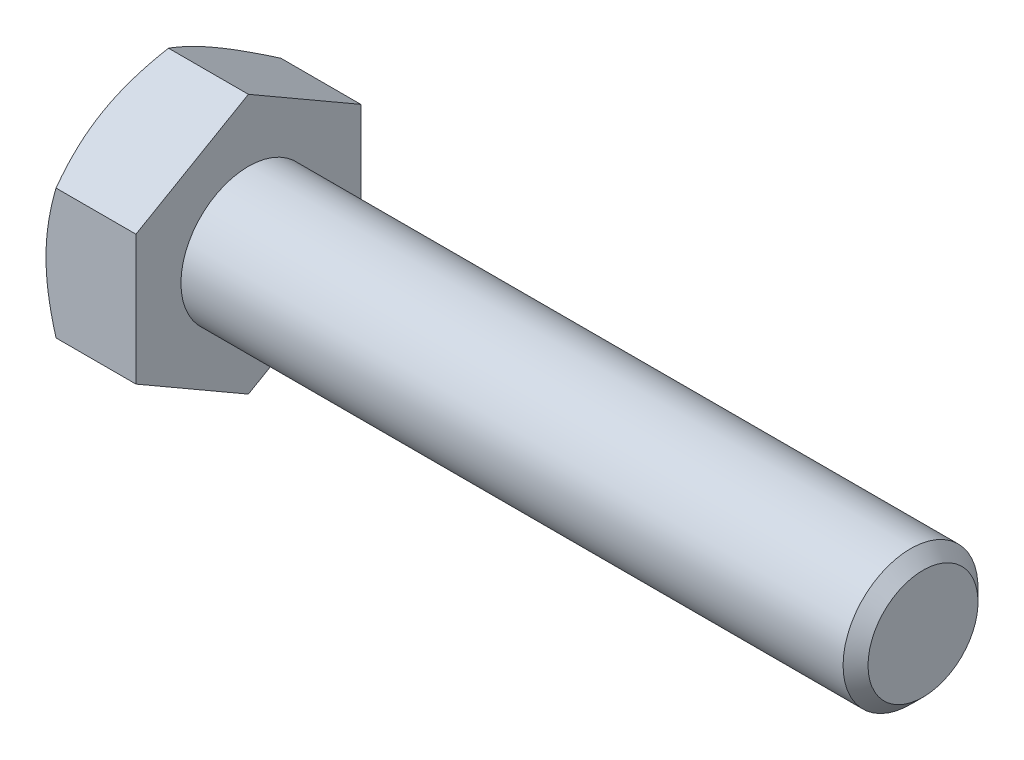
from build123d import *

# Parameters (mm, degrees)
BASEHEAD_DEPTH = 4


with BuildPart() as part:
    # Sketch1 → BaseHead (new body)
    with BuildSketch(Plane(origin=(0, 0, 0), x_dir=(0, 0, -1), z_dir=(1, 0, 0))):
        Polygon((5, 2.886751346), (5, -2.886751346), (0, -5.773502692), (-5, -2.886751346), (-5, 2.886751346), (0, 5.773502692), align=None)
    extrude(amount=BASEHEAD_DEPTH)

    # BodySke → BaseBody (revolve)
    with BuildSketch(Plane.XY):
        Polygon((0, 0), (34, 0), (34, 2.4455), (33.4455, 3), (0, 3), align=None)
    revolve(axis=Axis((0, 0, 0), (1, 0, 0)))

    # Sketch3 → HeadChamfer (revolve, cut)
    with BuildSketch(Plane.XY):
        Polygon((0, 5), (3.333333333, 10.773502692), (3.333333333, 15.773502692), (-10, 15.773502692), (-10, 5), align=None)
    revolve(axis=Axis((0, 0, 0), (1, 0, 0)), mode=Mode.SUBTRACT)


solid = part.part
